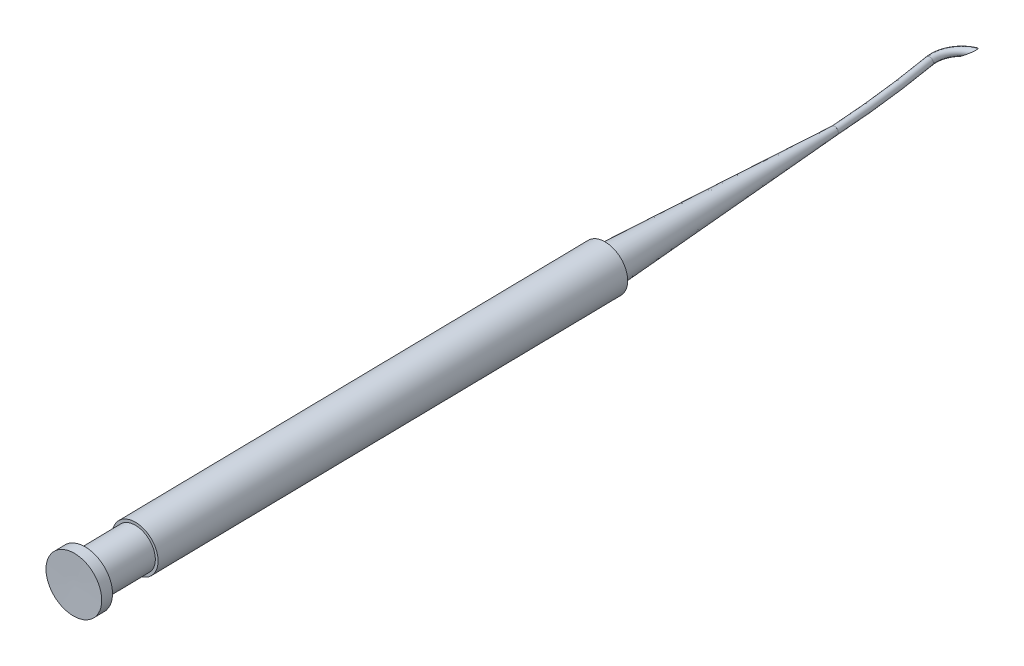
from build123d import *

# Parameters (mm, degrees)
SKETCH5_RX         = 0.499930018
SKETCH5_RY         = 0.499860046
SKETCH5_R          = 0.15
SKETCH7_W          = 2.34425361
SKETCH7_H          = 5.46465522
CUT_EXTRUDE1_DEPTH = 10


with BuildPart() as part:
    # Sketch2 → Revolve4 (revolve)
    with BuildSketch(Plane(origin=(0, 0, 0), x_dir=(1, 0, 0), z_dir=(0, 1, 0))):
        Polygon((24.886104147, 17.005765409), (26.107421074, -55.983659918), (29.857946011, -55.983659918), (29.832850335, -54.483869864), (28.807706852, -54.483869864), (28.690593697, -47.48484961), (29.065646191, -47.48484961), (27.972452613, 17.8475545), (27.163610623, 17.8475545), (24.837502632, 49.791775671), (24.337502632, 49.791775671), align=None)
    revolve(axis=Axis((24.886104147, 0, -17.005765409), (0.016730451, 0, 0.999860036)))


with BuildPart() as body_2:
    # Sweep1: sweep along a path in Sketch4
    with BuildLine(Plane(origin=(0, 0, 0), x_dir=(1, 0, 0), z_dir=(0, 1, 0))) as sweep1_path:
        ThreePointArc((24.337502632, 49.791775671), (23.66199483, 57.170782562), (22.582972321, 64.501659992))
        ThreePointArc((22.582972321, 64.501659992), (23.019193012, 67.040207811), (24.967268705, 68.725293748))
    # Sketch5 → Sweep1 (sweep)
    with BuildSketch(Plane(origin=(0, 5.85e-07, -49.791775671), x_dir=(-1, 0, 0), z_dir=(0, 1.2e-08, -1))):
        with Locations(Location((-24.337642586, -5.85e-07), (0, 0, -90.000040234))):
            Ellipse(SKETCH5_RX, SKETCH5_RY)
        with Locations((-24.337642586, -5.85e-07)):
            Circle(SKETCH5_R, mode=Mode.SUBTRACT)
    sweep(path=sweep1_path.line)

    # Sketch7 → Cut-Extrude1 (cut)
    with BuildSketch(Plane(origin=(10.399402023, -18.887006125, -3.280056559), x_dir=(0.300800703, 4e-09, 0.953687022), z_dir=(-0.476843512, 0.866025404, 0.150400349))):
        with Locations((-58.331941168, 37.298785896)):
            Rectangle(SKETCH7_W, SKETCH7_H)
    extrude(amount=-CUT_EXTRUDE1_DEPTH, mode=Mode.SUBTRACT)


solid = Compound([part.part, body_2.part])
